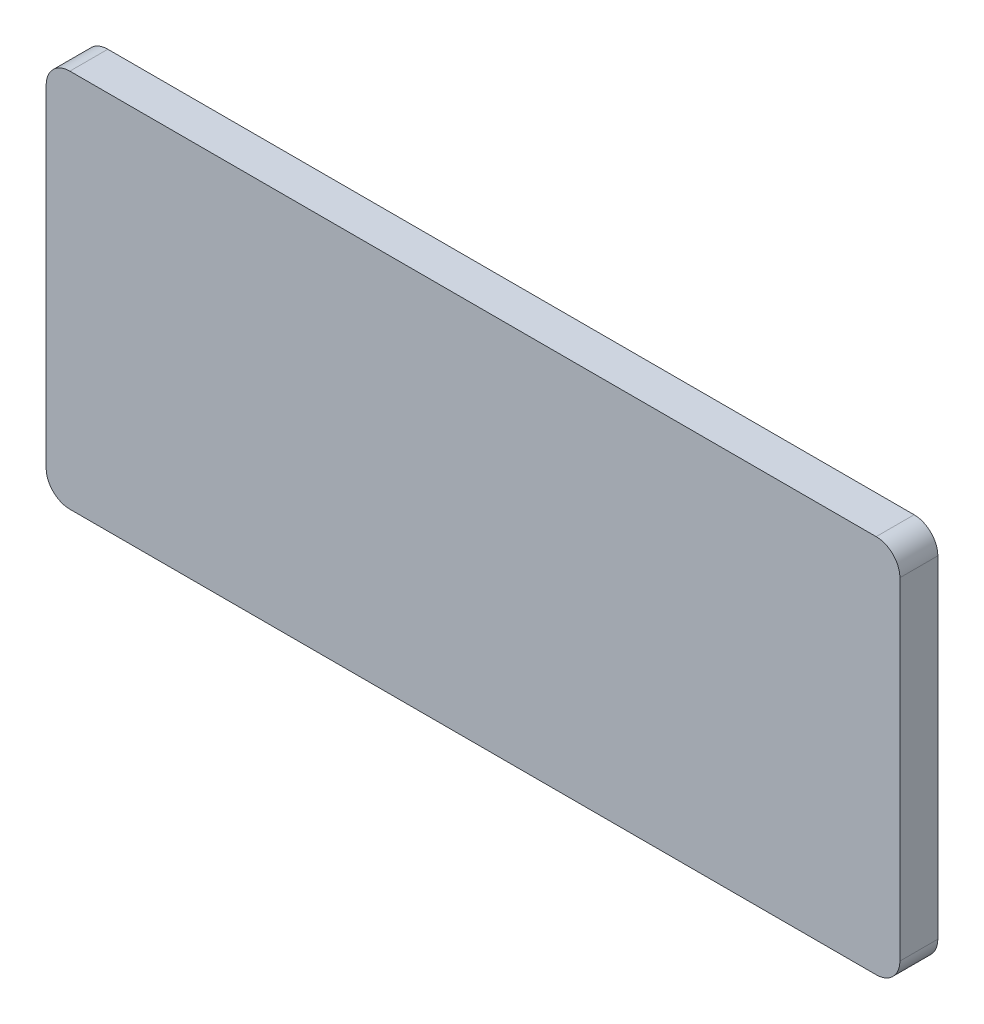
from build123d import *

# Parameters (mm, degrees)
EXTRUDE_1_DEPTH = 1.6


with BuildPart() as part:
    # 草图1 → 凸台-拉伸1 (new body)
    with BuildSketch(Plane.XY):
        with BuildLine():
            Line((-17, 8), (17, 8))
            ThreePointArc((17, 8), (17.707106781, 7.707106781), (18, 7))
            Line((18, 7), (18, -7))
            ThreePointArc((18, -7), (17.707106781, -7.707106781), (17, -8))
            Line((17, -8), (-17, -8))
            ThreePointArc((-17, -8), (-17.707106781, -7.707106781), (-18, -7))
            Line((-18, -7), (-18, 7))
            ThreePointArc((-18, 7), (-17.707106781, 7.707106781), (-17, 8))
        make_face()
    extrude(amount=EXTRUDE_1_DEPTH)


solid = part.part
